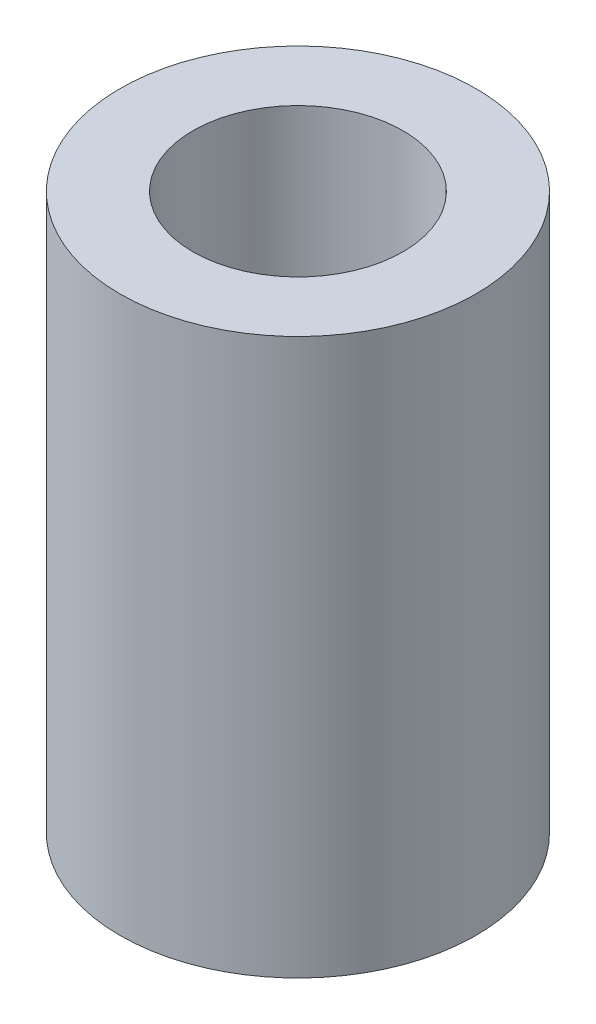
from build123d import *

# Parameters (mm, degrees)
SKETCH1_R           = 6.1
SKETCH1_R_2         = 3.6
BOSS_EXTRUDE1_DEPTH = 19.05


with BuildPart() as part:
    # Sketch1 → Boss-Extrude1 (new body)
    with BuildSketch(Plane(origin=(0, 0, 0), x_dir=(1, 0, 0), z_dir=(0, 1, 0))):
        Circle(SKETCH1_R)
        Circle(SKETCH1_R_2, mode=Mode.SUBTRACT)
    extrude(amount=BOSS_EXTRUDE1_DEPTH)


solid = part.part
